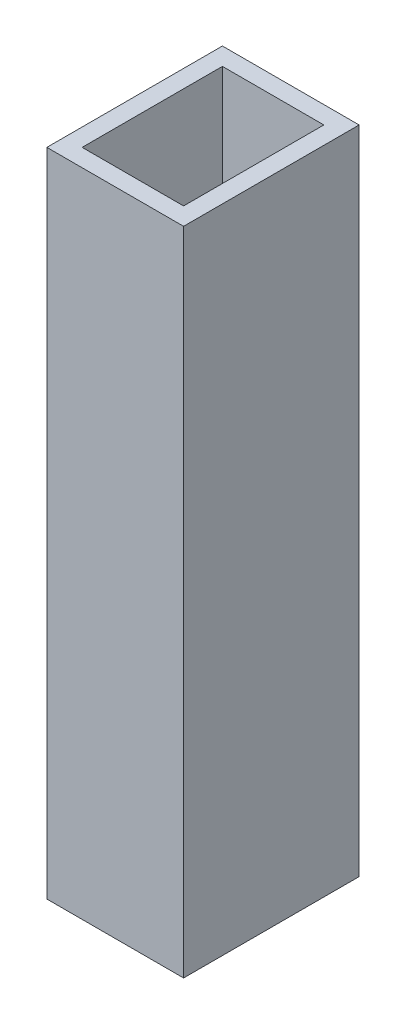
from build123d import *

# Parameters (mm, degrees)
BOSS_EXTRUDE1_DEPTH = 73.81
SHELL1_T            = -2


with BuildPart() as part:
    # Sketch2 → Boss-Extrude1 (new body)
    with BuildSketch(Plane(origin=(-7.134e-05, -112.600182523, -0.000896932), x_dir=(1, -6.34e-07, 0), z_dir=(-6.34e-07, -1, -7.966e-06))):
        Polygon((266.322967082, -12.059984739), (250.820606891, -12.059984722), (250.82060687, -31.964984722), (266.32296706, -31.964984739), align=None)
    extrude(amount=BOSS_EXTRUDE1_DEPTH)

    # Shell1
    shell1_openings = [part.faces().sort_by_distance(p)[0] for p in [
        (258.571715636, -112.600171002, -22.013381663),
    ]]
    offset(amount=SHELL1_T, openings=shell1_openings, kind=Kind.INTERSECTION)


solid = part.part
